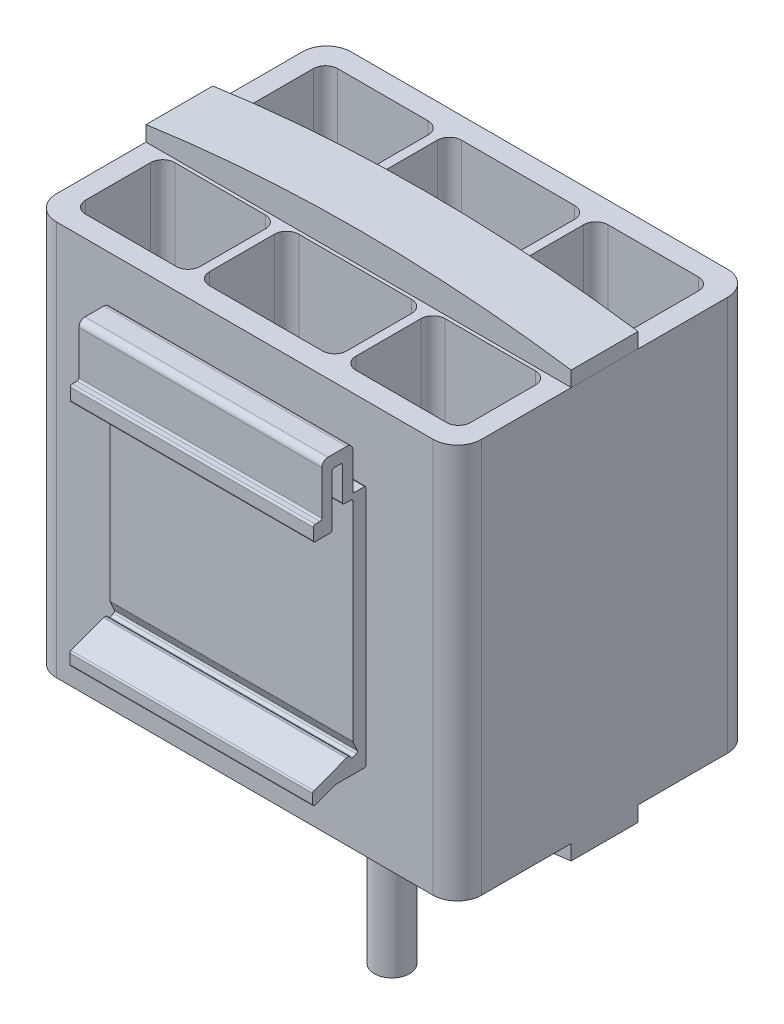
from build123d import *

# Parameters (mm, degrees)
SKETCH_1_W                  = 70
SKETCH_1_H                  = 65
EXTRUDE_1_DEPTH             = 48.5
CUT_EXTRUDE_1_REACH         = 67
SKETCH_2_W                  = 22.6
SKETCH_2_H                  = 14.7
SKETCH_2_W_2                = 18.9
SKETCH_3_W                  = 70
SKETCH_3_H                  = 11
EXTRUDE_2_DEPTH             = 5
CUT_EXTRUDE_4_DEPTH         = 11
EXTRUDE_3_REACH             = 26.25
EXTRUDE_3_DIRECTION_2_REACH = 26.25
EXTRUDE_6_DEPTH             = 20
FILLET_1_R                  = 4
FILLET_2_R                  = 2
SKETCH_13_OUTSIDE_W         = 97.154
SKETCH_13_OUTSIDE_H         = 84.454
SKETCH_13_OUTSIDE_R         = 5.5
CUT_EXTRUDE_8_DEPTH         = 3
SKETCH_14_R                 = 2.9
EXTRUDE_7_DEPTH             = 20


with BuildPart() as part:
    # Эскиз1 → Бобышка-Вытянуть1 (new body)
    with BuildSketch(Plane.XY):
        Rectangle(SKETCH_1_W, SKETCH_1_H)
    extrude(amount=EXTRUDE_1_DEPTH)

    # Эскиз2 → Вырез-Вытянуть1 (cut, up to next)
    with BuildSketch(Plane(origin=(0, 32.5, 0), x_dir=(1, 0, 0), z_dir=(0, 1, 0)), mode=Mode.PRIVATE) as cut_extrude_1_sk1:
        with Locations((0, -10.85)):
            Rectangle(SKETCH_2_W, SKETCH_2_H)
    cut_extrude_1_tool1 = extrude(cut_extrude_1_sk1.sketch, amount=-CUT_EXTRUDE_1_REACH, mode=Mode.PRIVATE) & part.part
    add(cut_extrude_1_tool1.solids().sort_by_distance((0, 32.5, 10.85))[0], mode=Mode.SUBTRACT)
    # Эскиз2 → Вырез-Вытянуть1 (cut, up to next)
    with BuildSketch(Plane(origin=(0, 32.5, 0), x_dir=(1, 0, 0), z_dir=(0, 1, 0)), mode=Mode.PRIVATE) as cut_extrude_1_sk2:
        with Locations((22.25, -10.85)):
            Rectangle(SKETCH_2_W_2, SKETCH_2_H)
    cut_extrude_1_tool2 = extrude(cut_extrude_1_sk2.sketch, amount=-CUT_EXTRUDE_1_REACH, mode=Mode.PRIVATE) & part.part
    add(cut_extrude_1_tool2.solids().sort_by_distance((22.25, 32.5, 10.85))[0], mode=Mode.SUBTRACT)
    # Эскиз2 → Вырез-Вытянуть1 (cut, up to next)
    with BuildSketch(Plane(origin=(0, 32.5, 0), x_dir=(1, 0, 0), z_dir=(0, 1, 0)), mode=Mode.PRIVATE) as cut_extrude_1_sk3:
        with Locations((-22.25, -10.85)):
            Rectangle(SKETCH_2_W_2, SKETCH_2_H)
    cut_extrude_1_tool3 = extrude(cut_extrude_1_sk3.sketch, amount=-CUT_EXTRUDE_1_REACH, mode=Mode.PRIVATE) & part.part
    add(cut_extrude_1_tool3.solids().sort_by_distance((-22.25, 32.5, 10.85))[0], mode=Mode.SUBTRACT)
    # Эскиз2 → Вырез-Вытянуть1 (cut, up to next)
    with BuildSketch(Plane(origin=(0, 32.5, 0), x_dir=(1, 0, 0), z_dir=(0, 1, 0)), mode=Mode.PRIVATE) as cut_extrude_1_sk4:
        with Locations((22.25, -37.65)):
            Rectangle(SKETCH_2_W_2, SKETCH_2_H)
    cut_extrude_1_tool4 = extrude(cut_extrude_1_sk4.sketch, amount=-CUT_EXTRUDE_1_REACH, mode=Mode.PRIVATE) & part.part
    add(cut_extrude_1_tool4.solids().sort_by_distance((22.25, 32.5, 37.65))[0], mode=Mode.SUBTRACT)
    # Эскиз2 → Вырез-Вытянуть1 (cut, up to next)
    with BuildSketch(Plane(origin=(0, 32.5, 0), x_dir=(1, 0, 0), z_dir=(0, 1, 0)), mode=Mode.PRIVATE) as cut_extrude_1_sk5:
        with Locations((0, -37.65)):
            Rectangle(SKETCH_2_W, SKETCH_2_H)
    cut_extrude_1_tool5 = extrude(cut_extrude_1_sk5.sketch, amount=-CUT_EXTRUDE_1_REACH, mode=Mode.PRIVATE) & part.part
    add(cut_extrude_1_tool5.solids().sort_by_distance((0, 32.5, 37.65))[0], mode=Mode.SUBTRACT)
    # Эскиз2 → Вырез-Вытянуть1 (cut, up to next)
    with BuildSketch(Plane(origin=(0, 32.5, 0), x_dir=(1, 0, 0), z_dir=(0, 1, 0)), mode=Mode.PRIVATE) as cut_extrude_1_sk6:
        with Locations((-22.25, -37.65)):
            Rectangle(SKETCH_2_W_2, SKETCH_2_H)
    cut_extrude_1_tool6 = extrude(cut_extrude_1_sk6.sketch, amount=-CUT_EXTRUDE_1_REACH, mode=Mode.PRIVATE) & part.part
    add(cut_extrude_1_tool6.solids().sort_by_distance((-22.25, 32.5, 37.65))[0], mode=Mode.SUBTRACT)


with BuildPart() as body_2:
    # Эскиз3 → Бобышка-Вытянуть2 (new body)
    with BuildSketch(Plane(origin=(0, 32.5, 0), x_dir=(1, 0, 0), z_dir=(0, 1, 0))):
        with Locations((0, -24.25)):
            Rectangle(SKETCH_3_W, SKETCH_3_H)
    extrude_2 = extrude(amount=EXTRUDE_2_DEPTH)

    # Эскиз4 → Вырез-Вытянуть4 (cut)
    with BuildSketch(Plane.XY.offset(29.75)):
        with BuildLine():
            Line((-35, 35), (-35, 41))
            Line((-35, 41), (35, 41))
            Line((35, 41), (35, 35))
            ThreePointArc((35, 35), (0, 37.5), (-35, 35))
        make_face()
    cut_extrude_4 = extrude(amount=-CUT_EXTRUDE_4_DEPTH, mode=Mode.SUBTRACT)


with BuildPart() as part_1:
    add(part.part)

    # Зеркальное отражение2: Бобышка-Вытянуть2, Вырез-Вытянуть4 across plane
    add(extrude_2.mirror(Plane.ZX))
    add(cut_extrude_4.mirror(Plane.ZX), mode=Mode.SUBTRACT)

    # Бобышка-Вытянуть3: up to this face of the body (flat: up to its plane)
    extrude_3_end = Plane(part_1.part.faces().sort_by_distance((0, -34.650725053, 18.75))[0])
    # Эскиз5 → Бобышка-Вытянуть3 (add, up to the picked face)
    with BuildSketch(Plane(origin=(0, 0, 24.25), x_dir=(-1, 0, 0), z_dir=(0, 0, -1)), mode=Mode.PRIVATE) as extrude_3_sk1:
        with BuildLine():
            Line((-11.5, -46.877385485), (-17.5, -36.877385485))
            ThreePointArc((-17.5, -36.877385485), (0, -37.5), (17.5, -36.877385485))
            Line((17.5, -36.877385485), (11.5, -46.877385485))
            Line((11.5, -46.877385485), (6.15, -46.877385485))
            Line((6.15, -46.877385485), (6.15, -49.877385485))
            Line((6.15, -49.877385485), (-6.15, -49.877385485))
            Line((-6.15, -49.877385485), (-6.15, -46.877385485))
            Line((-6.15, -46.877385485), (-11.5, -46.877385485))
        make_face()
    extrude_3_tool1 = split(extrude(extrude_3_sk1.sketch, amount=EXTRUDE_3_REACH, mode=Mode.PRIVATE), bisect_by=extrude_3_end, keep=Keep.BOTH, mode=Mode.PRIVATE)
    add(extrude_3_tool1.solids().sort_by(Axis((0, -42.546106, 24.25), (0, 0, -1)))[0])

    # Бобышка-Вытянуть3 direction 2: up to this face of the body (flat: up to its plane)
    extrude_3_direction_2_end = Plane(part_1.part.faces().sort_by_distance((0, -34.650725053, 29.75))[0])
    # Эскиз5 → Бобышка-Вытянуть3 direction 2 (add, up to the picked face)
    with BuildSketch(Plane(origin=(0, 0, 24.25), x_dir=(-1, 0, 0), z_dir=(0, 0, -1)), mode=Mode.PRIVATE) as extrude_3_direction_2_sk1:
        with BuildLine():
            Line((-11.5, -46.877385485), (-17.5, -36.877385485))
            ThreePointArc((-17.5, -36.877385485), (0, -37.5), (17.5, -36.877385485))
            Line((17.5, -36.877385485), (11.5, -46.877385485))
            Line((11.5, -46.877385485), (6.15, -46.877385485))
            Line((6.15, -46.877385485), (6.15, -49.877385485))
            Line((6.15, -49.877385485), (-6.15, -49.877385485))
            Line((-6.15, -49.877385485), (-6.15, -46.877385485))
            Line((-6.15, -46.877385485), (-11.5, -46.877385485))
        make_face()
    extrude_3_direction_2_tool1 = split(extrude(extrude_3_direction_2_sk1.sketch, amount=-EXTRUDE_3_DIRECTION_2_REACH, mode=Mode.PRIVATE), bisect_by=extrude_3_direction_2_end, keep=Keep.BOTH, mode=Mode.PRIVATE)
    add(extrude_3_direction_2_tool1.solids().sort_by(Axis((0, -42.546106, 24.25), (0, 0, 1)))[0])

    # Эскиз11 → Бобышка-Вытянуть6 (add, symmetric)
    with BuildSketch(Plane.ZY):
        with BuildLine():
            Line((48.8, -19.7), (53.446494712, -19.7))
            ThreePointArc((53.446494712, -19.7), (53.499168801, -19.704660466), (53.550206319, -19.718497065))
            Line((53.550206319, -19.718497065), (56.896288392, -20.951264145))
            ThreePointArc((56.896288392, -20.951264145), (57.171590381, -20.915844003), (57.3, -20.66976121))
            Line((57.3, -20.66976121), (57.3, -19.071198836))
            ThreePointArc((57.3, -19.071198836), (57.246082793, -18.899608455), (57.103711608, -18.789695901))
            Line((57.103711608, -18.789695901), (51.753314767, -16.818497065))
            ThreePointArc((51.753314767, -16.818497065), (51.702277249, -16.804660466), (51.649603159, -16.8))
            Line((51.649603159, -16.8), (51.395615132, -16.8))
            ThreePointArc((51.395615132, -16.8), (51.233596615, -16.847512377), (51.122897329, -16.975))
            Line((51.122897329, -16.975), (51.053098899, -17.127282197))
            ThreePointArc((51.053098899, -17.127282197), (50.884833356, -17.283511153), (50.655381096, -17.275))
            Line((50.655381096, -17.275), (50.10994549, -17.025))
            ThreePointArc((50.10994549, -17.025), (49.953716535, -16.856734457), (49.962227687, -16.627282197))
            Line((49.962227687, -16.627282197), (50.672717803, -15.077175771))
            ThreePointArc((50.672717803, -15.077175771), (50.693100103, -15.016147089), (50.7, -14.952175771))
            Line((50.7, -14.952175771), (50.7, 19.3))
            ThreePointArc((50.7, 19.3), (50.787867966, 19.512132034), (51, 19.6))
            Line((51, 19.6), (52.1, 19.6))
            ThreePointArc((52.1, 19.6), (52.312132034, 19.687867966), (52.4, 19.9))
            Line((52.4, 19.9), (52.4, 25.3))
            ThreePointArc((52.4, 25.3), (52.487867966, 25.512132034), (52.7, 25.6))
            Line((52.7, 25.6), (53.8, 25.6))
            ThreePointArc((53.8, 25.6), (54.012132034, 25.512132034), (54.1, 25.3))
            Line((54.1, 25.3), (54.1, 16.9))
            ThreePointArc((54.1, 16.9), (54.187867966, 16.687867966), (54.4, 16.6))
            Line((54.4, 16.6), (56.9, 16.6))
            ThreePointArc((56.9, 16.6), (57.112132034, 16.687867966), (57.2, 16.9))
            Line((57.2, 16.9), (57.2, 18.8))
            ThreePointArc((57.2, 18.8), (57.112132034, 19.012132034), (56.9, 19.1))
            Line((56.9, 19.1), (56.1, 19.1))
            ThreePointArc((56.1, 19.1), (55.887867966, 19.187867966), (55.8, 19.4))
            Line((55.8, 19.4), (55.8, 26.6))
            ThreePointArc((55.8, 26.6), (55.507106781, 27.307106781), (54.8, 27.6))
            Line((54.8, 27.6), (51.7, 27.6))
            ThreePointArc((51.7, 27.6), (50.992893219, 27.307106781), (50.7, 26.6))
            Line((50.7, 26.6), (50.7, 20.7))
            ThreePointArc((50.7, 20.7), (50.612132034, 20.487867966), (50.4, 20.4))
            Line((50.4, 20.4), (48.8, 20.4))
            ThreePointArc((48.8, 20.4), (48.587867966, 20.312132034), (48.5, 20.1))
            Line((48.5, 20.1), (48.5, -19.4))
            ThreePointArc((48.5, -19.4), (48.587867966, -19.612132034), (48.8, -19.7))
        make_face()
    extrude(amount=EXTRUDE_6_DEPTH, both=True)

    # Скругление1
    fillet_1_edges = [part_1.edges().sort_by_distance(p)[0] for p in [
        (-35, 0, 48.5),
        (35, 0, 48.5),
        (-35, 0, 0),
        (35, 0, 0),
    ]]
    fillet(fillet_1_edges, radius=FILLET_1_R)

    # Скругление2
    fillet_2_edges = [part_1.edges().sort_by_distance(p)[0] for p in [
        (31.7, 0, 3.5),
        (31.7, 0, 18.2),
        (12.8, 0, 18.2),
        (12.8, 0, 3.5),
        (-12.8, 0, 3.5),
        (-12.8, 0, 18.2),
        (-31.7, 0, 18.2),
        (-31.7, 0, 3.5),
        (12.8, 0, 45),
        (12.8, 0, 30.3),
        (31.7, 0, 30.3),
        (31.7, 0, 45),
        (-11.3, 0, 45),
        (-11.3, 0, 30.3),
        (11.3, 0, 30.3),
        (11.3, 0, 45),
        (-31.7, 0, 45),
        (-31.7, 0, 30.3),
        (-12.8, 0, 30.3),
        (-12.8, 0, 45),
        (11.3, 0, 3.5),
        (11.3, 0, 18.2),
        (-11.3, 0, 18.2),
        (-11.3, 0, 3.5),
    ]]
    fillet(fillet_2_edges, radius=FILLET_2_R)

    # Эскиз13 outside → Вырез-Вытянуть8 (cut)
    with BuildSketch(Plane.XZ.offset(49.877385485)):
        with Locations((0, 28.65)):
            Rectangle(SKETCH_13_OUTSIDE_W, SKETCH_13_OUTSIDE_H)
        with Locations(Location((0, 24.25, 0), (0, 0, 270))):  # turned: the seam where the file's is
            Circle(SKETCH_13_OUTSIDE_R, mode=Mode.SUBTRACT)
    extrude(amount=-CUT_EXTRUDE_8_DEPTH, mode=Mode.SUBTRACT)

    # Эскиз14 → Бобышка-Вытянуть7 (add)
    with BuildSketch(Plane.XZ.offset(49.877385485)):
        with Locations(Location((0, 24.25, 0), (0, 0, 270))):  # turned: the seam where the file's is
            Circle(SKETCH_14_R)
    extrude(amount=EXTRUDE_7_DEPTH)


solid = Compound([body_2.part, part_1.part])
